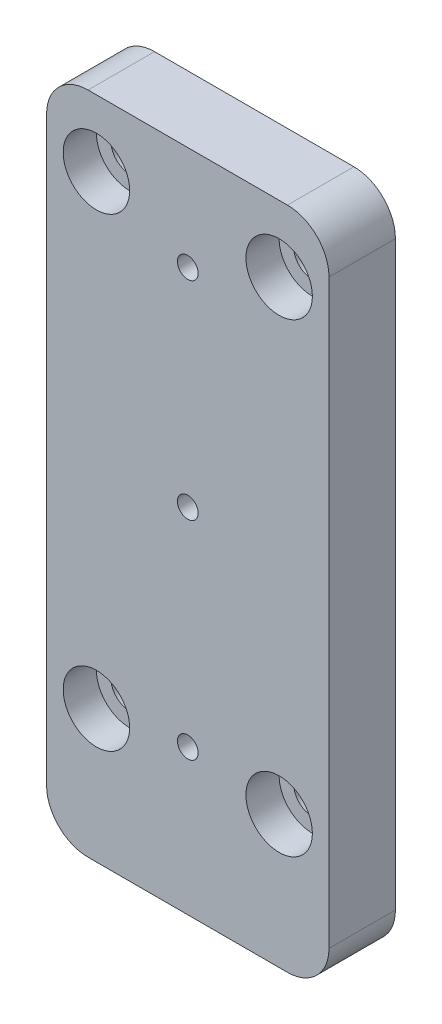
from build123d import *

# Parameters (mm, degrees)
ESQUISSE1_W                  = 34
ESQUISSE1_H                  = 80
BOSS_EXTRU_1_DEPTH           = 8
ESQUISSE2_R                  = 1.25
ENL_V_MAT_EXTRU_1_DEPTH      = 1
ENL_V_MAT_EXTRU_1_DEPTH_BACK = 9
ESQUISSE3_R                  = 2.25
ENL_V_MAT_EXTRU_2_DEPTH      = 1
ENL_V_MAT_EXTRU_2_DEPTH_BACK = 9
ESQUISSE4_R                  = 4
ENL_V_MAT_EXTRU_3_DEPTH      = 4
CONG_1_R                     = 5


with BuildPart() as part:
    # Esquisse1 → Boss.-Extru.1 (new body)
    with BuildSketch(Plane.XY):
        with Locations((17, 40)):
            Rectangle(ESQUISSE1_W, ESQUISSE1_H)
    extrude(amount=BOSS_EXTRU_1_DEPTH)

    # Esquisse2 → Enlèv. mat.-Extru.1 (cut, two sides)
    with BuildSketch(Plane.XY.offset(8)) as enl_v_mat_extru_1_sk:
        with Locations((17, 17.5)):
            Circle(ESQUISSE2_R)
        with Locations((17, 42.5)):
            Circle(ESQUISSE2_R)
        with Locations((17, 67.5)):
            Circle(ESQUISSE2_R)
        with Locations((17, 92.5)):
            Circle(ESQUISSE2_R)
        with Locations((17, 117.5)):
            Circle(ESQUISSE2_R)
        with Locations((17, 142.5)):
            Circle(ESQUISSE2_R)
        with Locations((17, 167.5)):
            Circle(ESQUISSE2_R)
        with Locations((17, 192.5)):
            Circle(ESQUISSE2_R)
    extrude(amount=ENL_V_MAT_EXTRU_1_DEPTH, mode=Mode.SUBTRACT)
    extrude(enl_v_mat_extru_1_sk.sketch, amount=-ENL_V_MAT_EXTRU_1_DEPTH_BACK, mode=Mode.SUBTRACT)

    # Esquisse3 → Enlèv. mat.-Extru.2 (cut, two sides)
    with BuildSketch(Plane.XY.offset(8)) as enl_v_mat_extru_2_sk:
        with Locations((6, 16)):
            Circle(ESQUISSE3_R)
        with Locations((28, 16)):
            Circle(ESQUISSE3_R)
        with Locations((28, 72)):
            Circle(ESQUISSE3_R)
        with Locations((6, 72)):
            Circle(ESQUISSE3_R)
    extrude(amount=ENL_V_MAT_EXTRU_2_DEPTH, mode=Mode.SUBTRACT)
    extrude(enl_v_mat_extru_2_sk.sketch, amount=-ENL_V_MAT_EXTRU_2_DEPTH_BACK, mode=Mode.SUBTRACT)

    # Esquisse4 → Enlèv. mat.-Extru.3 (cut)
    with BuildSketch(Plane.XY.offset(8)):
        with Locations((6, 16)):
            Circle(ESQUISSE4_R)
        with Locations((28, 16)):
            Circle(ESQUISSE4_R)
        with Locations((6, 72)):
            Circle(ESQUISSE4_R)
        with Locations((28, 72)):
            Circle(ESQUISSE4_R)
    extrude(amount=-ENL_V_MAT_EXTRU_3_DEPTH, mode=Mode.SUBTRACT)

    # Congé1
    cong_1_edges = [part.edges().sort_by_distance(p)[0] for p in [
        (0, 80, 4),
        (34, 80, 4),
        (34, 0, 4),
        (0, 0, 4),
    ]]
    fillet(cong_1_edges, radius=CONG_1_R)


solid = part.part
